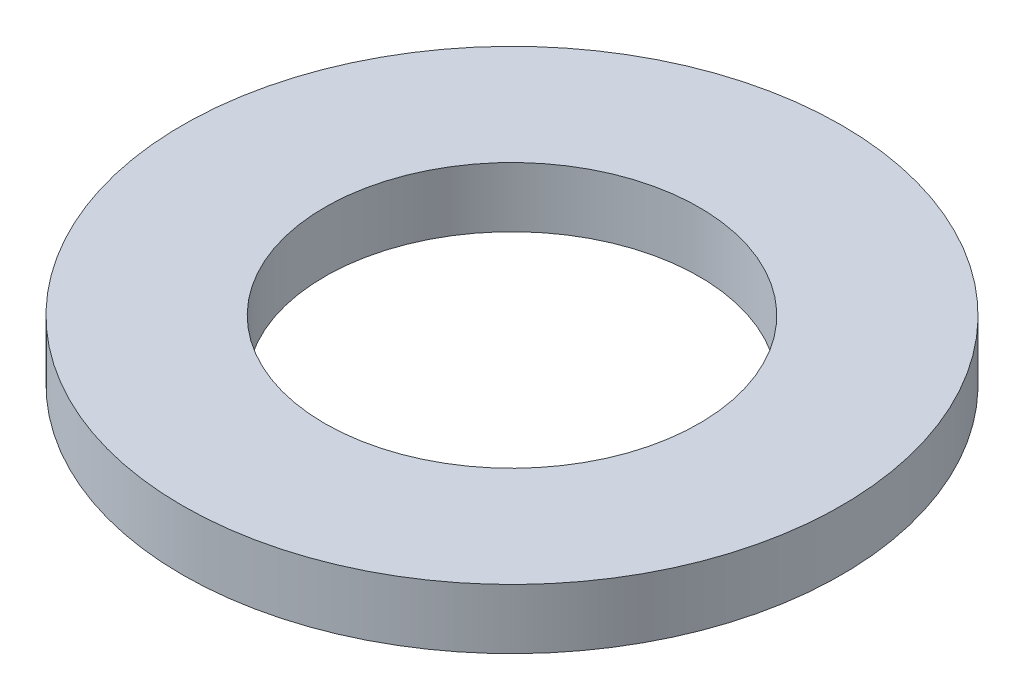
from build123d import *

# Parameters (mm, degrees)
SKETCH1_R           = 22
SKETCH1_R_2         = 12.5
BOSS_EXTRUDE1_DEPTH = 4


with BuildPart() as part:
    # Sketch1 → Boss-Extrude1 (new body)
    with BuildSketch(Plane(origin=(0, 0, 0), x_dir=(1, 0, 0), z_dir=(0, 1, 0))):
        Circle(SKETCH1_R)
        Circle(SKETCH1_R_2, mode=Mode.SUBTRACT)
    extrude(amount=BOSS_EXTRUDE1_DEPTH)


solid = part.part
